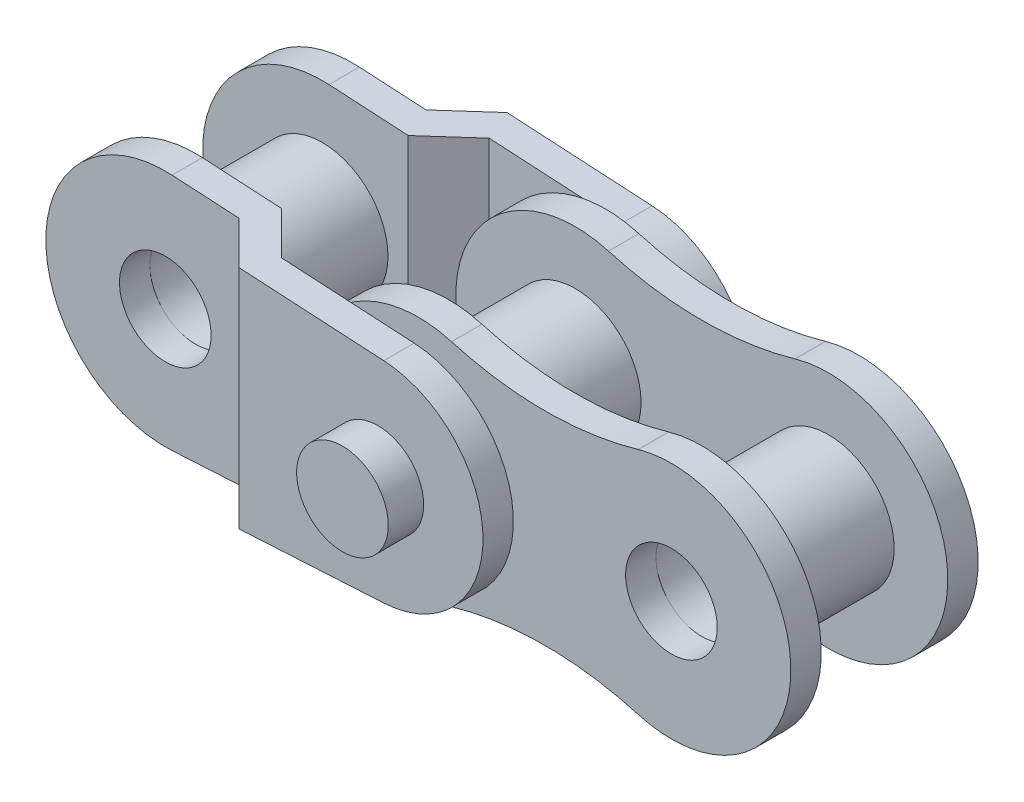
from build123d import *

# Parameters (mm, degrees)
SKETCH4_R               = 1.651
SKETCH4_R_2             = 1.17475
BOSS_EXTRUDE1_DEPTH     = 1.5875
LPATTERN1_COUNT         = 3
LPATTERN1_PITCH         = 6.35
SKETCH8_R               = 1.14935
BOSS_EXTRUDE4_DEPTH     = 4.2545
SKETCH15_R              = 1.14935
BOSS_EXTRUDE6_DEPTH     = 0.762
SKETCH9_R               = 1.14935
BOSS_EXTRUDE5_DEPTH     = 3.3655
CUT_EXTRUDE1_DEPTH      = 3.9972
CUT_EXTRUDE1_DEPTH_BACK = 3.9972


with BuildPart() as part:
    # Sketch4 → Boss-Extrude1 (new body, symmetric)
    with BuildSketch(Plane.XY):
        with Locations((-3.175, 0)):
            Circle(SKETCH4_R)
        with Locations((-3.175, 0)):
            Circle(SKETCH4_R_2, mode=Mode.SUBTRACT)
    extrude(amount=BOSS_EXTRUDE1_DEPTH, both=True)


with BuildPart() as lpattern1_1:
    # LPattern1: pattern copy
    add(part.part.moved(Location(Vector(1, 0, 0) * (1 * LPATTERN1_PITCH))))


with BuildPart() as lpattern1_2:
    # LPattern1: pattern copy
    add(part.part.moved(Location(Vector(1, 0, 0) * (2 * LPATTERN1_PITCH))))


with BuildPart() as body_4:
    # Sketch8 → Boss-Extrude4 (new body, symmetric)
    with BuildSketch(Plane.XY):
        with Locations((3.175, 0)):
            Circle(SKETCH8_R)
    extrude(amount=BOSS_EXTRUDE4_DEPTH, both=True)


with BuildPart() as body_5:
    # Sketch15 → Boss-Extrude6 (new body)
    with BuildSketch(Plane.XY.offset(1.5875)):
        with BuildLine():
            ThreePointArc((-2.342877482, 2.879371452), (-6.1722, 0), (-2.342877482, -2.879371452))
            ThreePointArc((-2.342877482, -2.879371452), (0, -2.54762), (2.342877482, -2.879371452))
            ThreePointArc((2.342877482, -2.879371452), (6.1722, 0), (2.342877482, 2.879371452))
            ThreePointArc((2.342877482, 2.879371452), (0, 2.54762), (-2.342877482, 2.879371452))
        make_face()
        with Locations((-3.175, 0)):
            Circle(SKETCH15_R, mode=Mode.SUBTRACT)
        with Locations((3.175, 0)):
            Circle(SKETCH15_R, mode=Mode.SUBTRACT)
    extrude(amount=BOSS_EXTRUDE6_DEPTH)


with BuildPart() as body_6:
    # Mirror3: mirrored copy
    add(body_5.part.mirror(Plane.XY))


with BuildPart() as body_6_1:
    # Body-Move/Copy1: moved
    add(body_6.part.moved(Location((6.35, 0, 0))))


with BuildPart() as body_5_1:
    # Body-Move/Copy1: moved
    add(body_5.part.moved(Location((6.35, 0, 0))))


with BuildPart() as body_7:
    # Sketch9 → Boss-Extrude5 (new body)
    with BuildSketch(Plane.XY):
        with BuildLine():
            Line((-3.005238592, 2.992388495), (3.324390039, 2.633301876))
            ThreePointArc((3.324390039, 2.633301876), (5.812536, 0), (3.324390039, -2.633301876))
            Line((3.324390039, -2.633301876), (-3.005238592, -2.992388495))
            ThreePointArc((-3.005238592, -2.992388495), (-6.1722, 0), (-3.005238592, 2.992388495))
        make_face()
        with Locations((-3.175, 0)):
            Circle(SKETCH9_R, mode=Mode.SUBTRACT)
        with Locations((3.175, 0)):
            Circle(SKETCH9_R, mode=Mode.SUBTRACT)
    extrude(amount=-BOSS_EXTRUDE5_DEPTH)

    # Sketch10 → Cut-Extrude1 (cut, two sides)
    with BuildSketch(Plane(origin=(0, 0, 0), x_dir=(1, 0, 0), z_dir=(0, 1, 0))) as cut_extrude1_sk:
        Polygon((-6.1722, 2.3495), (-1.331630735, 2.3495), (-0.315630735, 3.3655), (-6.1722, 3.3655), align=None)
        Polygon((-6.1722, 1.5875), (-1.016, 1.5875), (0, 2.6035), (6.1722, 2.6035), (6.1722, 0), (-6.1722, 0), align=None)
    extrude(amount=CUT_EXTRUDE1_DEPTH, mode=Mode.SUBTRACT)
    extrude(cut_extrude1_sk.sketch, amount=-CUT_EXTRUDE1_DEPTH_BACK, mode=Mode.SUBTRACT)


with BuildPart() as body_8:
    # Mirror1: mirrored copy
    add(body_7.part.mirror(Plane.XY))


solid = Compound([part.part, lpattern1_1.part, lpattern1_2.part, body_4.part, body_6_1.part, body_5_1.part, body_7.part, body_8.part])
